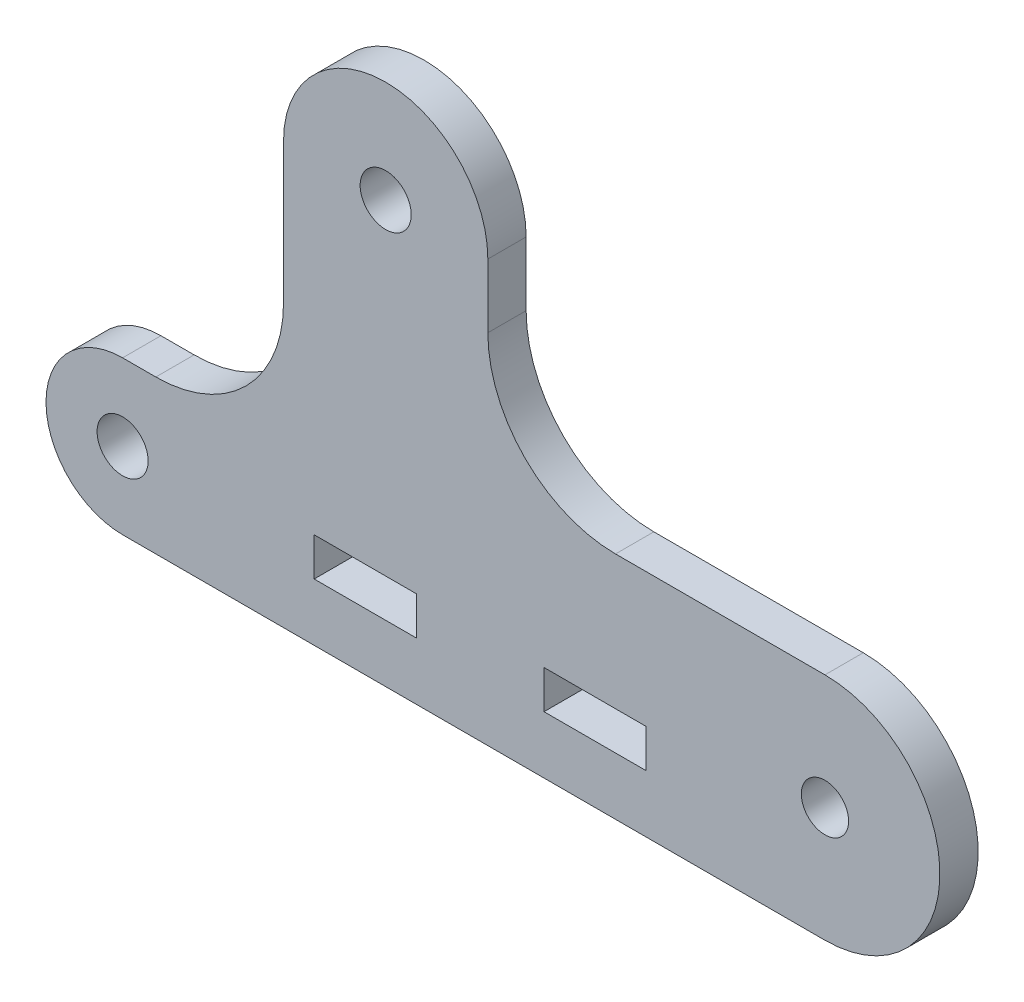
from build123d import *

# Parameters (mm, degrees)
SKETCH1_R           = 2
SKETCH1_R_2         = 1.85
SKETCH1_W           = 8
SKETCH1_H           = 3
BOSS_EXTRUDE1_DEPTH = 1.5


with BuildPart() as part:
    # Sketch1 → Boss-Extrude1 (new body, symmetric)
    with BuildSketch(Plane.XY):
        with BuildLine():
            Line((-27.5, 0), (27.5, 0))
            ThreePointArc((27.5, 0), (36.5, 9), (27.5, 18))
            Line((27.5, 18), (11.1, 18))
            ThreePointArc((11.1, 18), (4.028932188, 20.928932188), (1.1, 28))
            Line((1.1, 28), (1.1, 33))
            ThreePointArc((1.1, 33), (-6.9, 41), (-14.9, 33))
            Line((-14.9, 33), (-14.9, 22))
            ThreePointArc((-14.9, 22), (-17.828932188, 14.928932188), (-24.9, 12))
            Line((-24.9, 12), (-27.5, 12))
            ThreePointArc((-27.5, 12), (-33.5, 6), (-27.5, 0))
        make_face()
        with Locations((-27.5, 6)):
            Circle(SKETCH1_R, mode=Mode.SUBTRACT)
        with Locations((27.5, 9)):
            Circle(SKETCH1_R_2, mode=Mode.SUBTRACT)
        with Locations((-6.9, 33)):
            Circle(SKETCH1_R, mode=Mode.SUBTRACT)
        with Locations((-8.5, 6)):
            Rectangle(SKETCH1_W, SKETCH1_H, mode=Mode.SUBTRACT)
        with Locations((9.5, 6)):
            Rectangle(SKETCH1_W, SKETCH1_H, mode=Mode.SUBTRACT)
    extrude(amount=BOSS_EXTRUDE1_DEPTH, both=True)


solid = part.part
